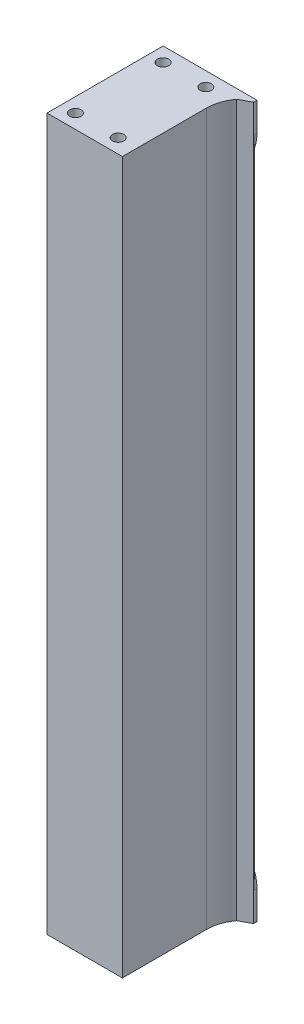
from build123d import *

# Parameters (mm, degrees)
BOSS_EXTRUDE1_DEPTH = 250
BOSS_EXTRUDE2_DEPTH = 0.8
SKETCH3_R           = 2
CUT_EXTRUDE2_DEPTH  = 8
FILLET1_R           = 5
SKETCH4_R           = 2
CUT_EXTRUDE3_DEPTH  = 8


with BuildPart() as part:
    # Sketch1 → Boss-Extrude1 (new body)
    with BuildSketch(Plane(origin=(0, 0, 0), x_dir=(1, 0, 0), z_dir=(0, 1, 0))):
        with BuildLine():
            Line((6.5, 9.5), (6.5, -20))
            Line((6.5, -20), (-20, -20))
            Line((-20, -20), (-20, 20))
            Line((-20, 20), (13, 20))
            Line((13, 20), (13, 19.6))
            Line((13, 19.6), (9.125718415, 17.5))
            ThreePointArc((9.125718415, 17.5), (7.173215496, 13.709940534), (6.5, 9.5))
        make_face()
    extrude(amount=BOSS_EXTRUDE1_DEPTH)

    # Sketch2 → Boss-Extrude2 (add)
    with BuildSketch(Plane(origin=(0, 0, -20), x_dir=(-1, 0, 0), z_dir=(0, 0, -1))):
        with BuildLine():
            Line((20, 225), (20, 250))
            Line((20, 250), (-13, 250))
            Line((-13, 250), (-13, 240))
            ThreePointArc((-13, 240), (-8.606601718, 229.393398282), (2, 225))
            Line((2, 225), (20, 225))
        make_face()
        with BuildLine():
            Line((-13, 0), (-13, 10))
            ThreePointArc((-13, 10), (-8.606601718, 20.606601718), (2, 25))
            Line((2, 25), (20, 25))
            Line((20, 25), (20, 0))
            Line((20, 0), (-13, 0))
        make_face()
    extrude(amount=BOSS_EXTRUDE2_DEPTH)

    # Sketch3 → Cut-Extrude2 (cut)
    with BuildSketch(Plane.XZ):
        with Locations((-15, 15)):
            Circle(SKETCH3_R)
        with Locations((0, 15)):
            Circle(SKETCH3_R)
        with Locations((0, -15.8)):
            Circle(SKETCH3_R)
        with Locations((-15, -15.8)):
            Circle(SKETCH3_R)
    cut_extrude2 = extrude(amount=-CUT_EXTRUDE2_DEPTH, mode=Mode.SUBTRACT)

    # Mirror1: Cut-Extrude2 across plane
    add(cut_extrude2.mirror(Plane.ZX.offset(125)), mode=Mode.SUBTRACT)

    # Fillet1
    fillet1_edges = [part.edges().sort_by_distance(p)[0] for p in [
        (-20, 125, -20),
    ]]
    fillet(fillet1_edges, radius=FILLET1_R)

    # Sketch4 → Cut-Extrude3 (cut)
    with BuildSketch(Plane(origin=(0, 0, -20.8), x_dir=(-1, 0, 0), z_dir=(0, 0, -1))):
        with Locations((5, 240)):
            Circle(SKETCH4_R)
    cut_extrude3 = extrude(amount=-CUT_EXTRUDE3_DEPTH, mode=Mode.SUBTRACT)

    # Mirror2: Cut-Extrude3 across plane
    add(cut_extrude3.mirror(Plane.ZX.offset(125)), mode=Mode.SUBTRACT)


solid = part.part
